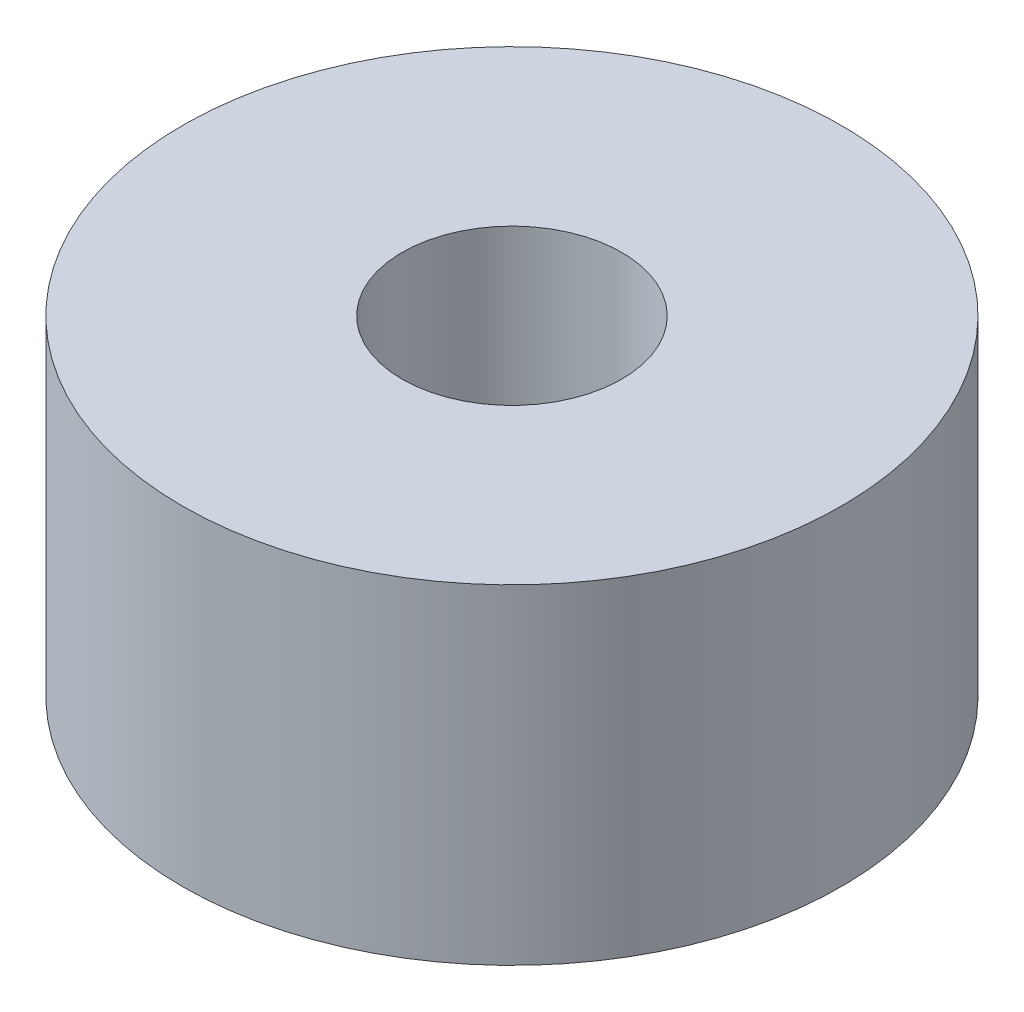
from build123d import *

# Parameters (mm, degrees)
SKETCH_1_R      = 3
SKETCH_1_R_2    = 1
EXTRUDE_1_DEPTH = 3


with BuildPart() as part:
    # 草图1 → 凸台-拉伸1 (new body)
    with BuildSketch(Plane(origin=(0, 0, 0), x_dir=(1, 0, 0), z_dir=(0, 1, 0))):
        Circle(SKETCH_1_R)
        Circle(SKETCH_1_R_2, mode=Mode.SUBTRACT)
    extrude(amount=EXTRUDE_1_DEPTH)


solid = part.part
